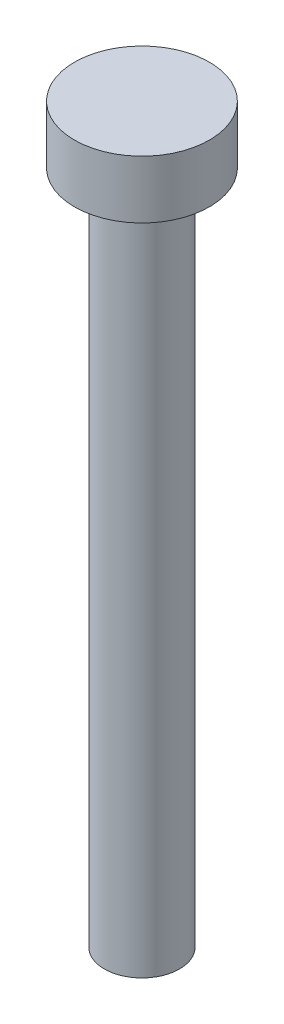
from build123d import *

# Parameters (mm, degrees)
SKETCH1_R           = 3.5
BOSS_EXTRUDE1_DEPTH = 3
SKETCH2_R           = 1.95
BOSS_EXTRUDE2_DEPTH = 35


with BuildPart() as part:
    # Sketch1 → Boss-Extrude1 (new body)
    with BuildSketch(Plane(origin=(0, 0, 0), x_dir=(1, 0, 0), z_dir=(0, 1, 0))):
        Circle(SKETCH1_R)
    extrude(amount=BOSS_EXTRUDE1_DEPTH)

    # Sketch2 → Boss-Extrude2 (add)
    with BuildSketch(Plane.XZ):
        Circle(SKETCH2_R)
    extrude(amount=BOSS_EXTRUDE2_DEPTH)


solid = part.part
